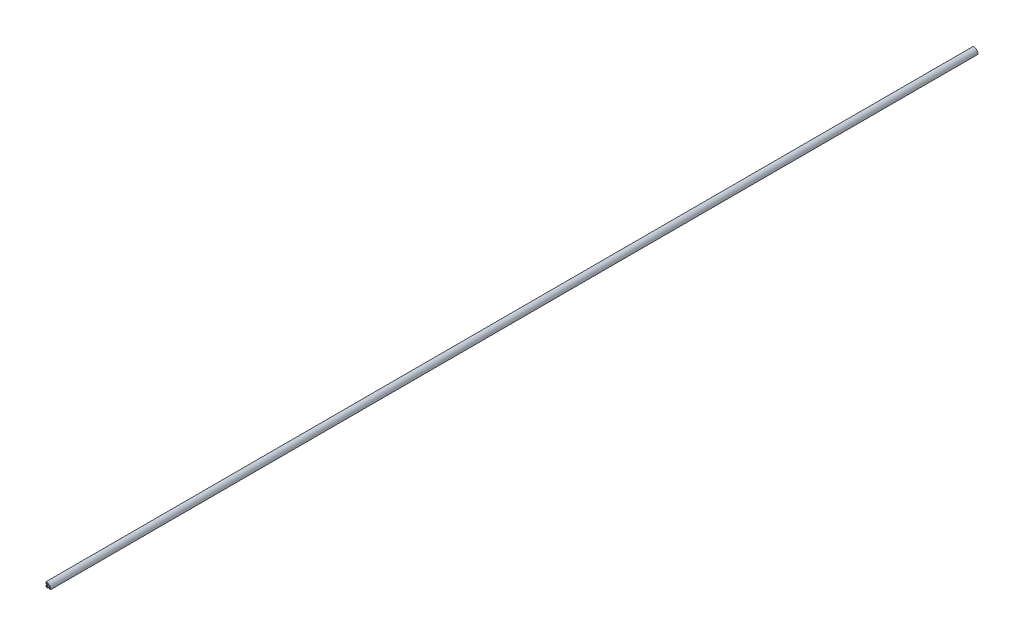
from build123d import *

# Parameters (mm, degrees)
SKETCH1_R          = 6.05
EXTRUDE1_DEPTH     = 6000
CUT_EXTRUDE1_DEPTH = 6001


with BuildPart() as part:
    # Sketch1 → Extrude1 (new body)
    with BuildSketch(Plane.XY):
        with BuildLine():
            Line((-11.292893, -9.171573), (-13, -9.171573))
            Line((-13, -9.171573), (-13, -4))
            Line((-13, -4), (-15, -4))
            Line((-15, -4), (-15, -15))
            Line((-15, -15), (-3.999999934, -15))
            Line((-3.999999934, -15), (-3.999999934, -13))
            Line((-3.999999934, -13), (-9.171572934, -13))
            Line((-9.171572934, -13), (-9.171572934, -11.292893))
            Line((-9.171572934, -11.292893), (-5.478679934, -7.6))
            Line((-5.478679934, -7.6), (3.231371323, -7.6))
            Line((3.231371323, -7.6), (7.265685066, -11.634315))
            Line((7.265685066, -11.634315), (7.265685066, -13))
            Line((7.265685066, -13), (4.000000066, -13))
            Line((4.000000066, -13), (4.000000066, -15))
            Line((4.000000066, -15), (15.001499931, -15))
            ThreePointArc((15.001499931, -15), (6.214264035, 6.214264026), (-15, 15.001499898))
            Line((-15, 15.001499898), (-15, 4))
            Line((-15, 4), (-13, 4))
            Line((-13, 4), (-13, 7.265685))
            Line((-13, 7.265685), (-11.634315, 7.265685))
            Line((-11.634315, 7.265685), (-7.6, 3.231371278))
            Line((-7.6, 3.231371278), (-7.6, -5.47868))
            Line((-7.6, -5.47868), (-11.292893, -9.171573))
        make_face()
        Circle(SKETCH1_R, mode=Mode.SUBTRACT)
    extrude(amount=-EXTRUDE1_DEPTH)

    # Sketch2 → Cut-Extrude1 (cut, through all)
    with BuildSketch(Plane.XY):
        with BuildLine():
            Line((6.05, 0), (8.022374154, 0))
            ThreePointArc((8.022374154, 0), (11.301094724, -6.107256592), (12.434393171, -12.945694008))
            Line((12.434393171, -12.945694008), (8.519597612, -12.945694008))
            Line((8.519597612, -12.945694008), (8.519597612, -11.049532451))
            Line((8.519597612, -11.049532451), (2.821731423, -5.351666262))
            ThreePointArc((2.821731423, -5.351666262), (-4.345433196, -4.20947863), (-5.259300556, 2.990360792))
            Line((-5.259300556, 2.990360792), (-10.801843855, 8.532904091))
            Line((-10.801843855, 8.532904091), (-13.012013608, 8.532904091))
            Line((-13.012013608, 8.532904091), (-13.012013608, 12.481450922))
            ThreePointArc((-13.012013608, 12.481450922), (-6.127642695, 11.324212583), (0, 7.979700895))
            Line((0, 7.979700895), (0, 6.05))
            ThreePointArc((0, 6.05), (4.277996026, 4.277996026), (6.05, 0))
        make_face()
    extrude(amount=-CUT_EXTRUDE1_DEPTH, mode=Mode.SUBTRACT)


solid = part.part
